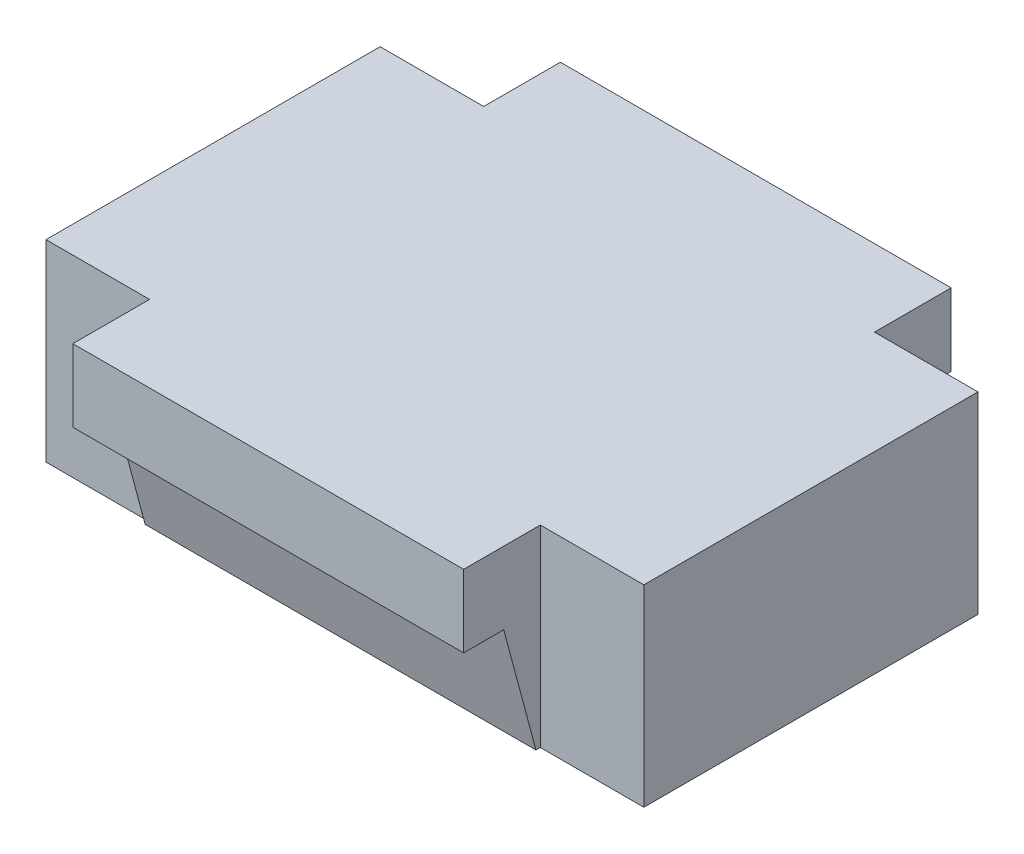
from build123d import *

# Parameters (mm, degrees)
BOSS_EXTRUDE1_DEPTH = 38.63
BOSS_EXTRUDE2_DEPTH = 25.25
SKETCH13_W          = 26.671300946
SKETCH13_H          = 17.817336211
BOSS_EXTRUDE3_DEPTH = 77.26
BOSS_EXTRUDE4_DEPTH = 50.5
SKETCH15_W          = 43.18
SKETCH15_H          = 24.9
BOSS_EXTRUDE5_DEPTH = 77.26


with BuildPart() as part:
    # Sketch2 → Boss-Extrude1 (new body)
    with BuildSketch(Plane(origin=(0, 0, 0), x_dir=(0, 0, -1), z_dir=(1, 0, 0))):
        with BuildLine():
            Line((-8.235, -8.9), (-20.12, -8.9))
            Line((-20.12, -8.9), (-21.59, -7.43))
            Line((-21.59, -7.43), (-21.59, 14.03))
            Line((-21.59, 14.03), (-20.12, 15.5))
            Line((-20.12, 15.5), (0, 15.5))
            Line((0, 15.5), (0, 3.015))
            Line((0, 3.015), (-7.65, 3.015))
            Line((-7.65, 3.015), (-8.003553391, 2.661446609))
            ThreePointArc((-8.003553391, 2.661446609), (-8.484745674, 1.499745674), (-9.646446609, 1.018553391))
            Line((-9.646446609, 1.018553391), (-10, 0.665))
            Line((-10, 0.665), (-10, -0.665))
            Line((-10, -0.665), (-9.646446609, -1.018553391))
            ThreePointArc((-9.646446609, -1.018553391), (-8.484745674, -1.499745674), (-8.003553391, -2.661446609))
            Line((-8.003553391, -2.661446609), (-6.5, -4.165))
            Line((-6.5, -4.165), (-6.5, -7.165))
            Line((-6.5, -7.165), (-8.235, -8.9))
        make_face()
    extrude(amount=BOSS_EXTRUDE1_DEPTH)

    # Sketch3 → Boss-Extrude2 (add)
    with BuildSketch(Plane(origin=(0, 0, 0), x_dir=(0, 0, -1), z_dir=(1, 0, 0))):
        Polygon((-20.12, -8.9), (-21.12, -8.9), (-22.534213562, -7.485786438), (-26.320335651, 6.644213562), (-31.5, 6.644213562), (-31.5, 16), (-20.855, 16), (-20.855, 15.6), (-5.355, 15.6), (-5.355, 16), (0, 16), (0, 15.5), (-20.12, 15.5), (-21.59, 14.03), (-21.59, -7.43), align=None)
    extrude(amount=BOSS_EXTRUDE2_DEPTH)

    # Mirror1: part across plane


with BuildPart() as part_1:
    add(part.part)
    add(part.part.mirror(Plane.XY))

    # Mirror2: part across plane


with BuildPart() as part_2:
    add(part_1.part)
    add(part_1.part.mirror(Plane(origin=(0, 0, 0), x_dir=(0, 0, 1), z_dir=(1, 0, 0))))

    # Sketch13 → Boss-Extrude3 (add)
    with BuildSketch(Plane(origin=(38.63, 0, 0), x_dir=(0, 0, -1), z_dir=(1, 0, 0))):
        with Locations((0.075172776, 0.008668105)):
            Rectangle(SKETCH13_W, SKETCH13_H)
    extrude(amount=-BOSS_EXTRUDE3_DEPTH)

    # Sketch14 → Boss-Extrude4 (add)
    with BuildSketch(Plane(origin=(25.25, 0, 0), x_dir=(0, 0, -1), z_dir=(1, 0, 0))):
        Polygon((-31.5, 16), (31.5, 16), (31.5, 6.644213562), (26.320335651, 6.644213562), (22.15527618, -8.9), (-22.15527618, -8.9), (-26.320335651, 6.644213562), (-31.5, 6.644213562), align=None)
    extrude(amount=-BOSS_EXTRUDE4_DEPTH)

    # Sketch15 → Boss-Extrude5 (add)
    with BuildSketch(Plane(origin=(38.63, 0, 0), x_dir=(0, 0, -1), z_dir=(1, 0, 0))):
        with Locations((0, 3.55)):
            Rectangle(SKETCH15_W, SKETCH15_H)
    extrude(amount=-BOSS_EXTRUDE5_DEPTH)


solid = part_2.part
